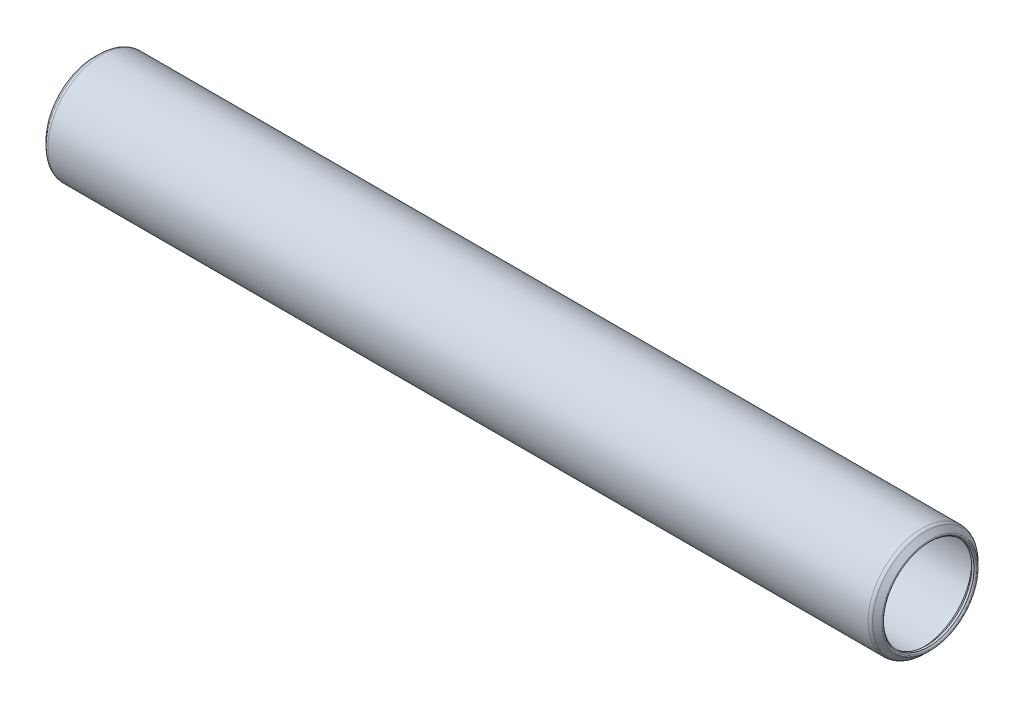
from build123d import *


with BuildPart() as part:
    # Sketch1 → Revolve1 (revolve)
    with BuildSketch(Plane.XY):
        with BuildLine():
            Line((-0.396407684, 5.304957684), (-0.254, 5.16255))
            Line((-0.254, 5.16255), (0, 5.16255))
            Line((0, 5.16255), (0.508, 5.67055))
            Line((0.508, 5.67055), (93.9292, 5.67055))
            Line((93.9292, 5.67055), (94.4372, 5.16255))
            Line((94.4372, 5.16255), (94.6912, 5.16255))
            Line((94.6912, 5.16255), (94.833607684, 5.304957684))
            ThreePointArc((94.833607684, 5.304957684), (94.870805122, 5.394760245), (94.833607684, 5.484562806))
            Line((94.833607684, 5.484562806), (94.301110245, 6.017060245))
            ThreePointArc((94.301110245, 6.017060245), (94.136303184, 6.127180803), (93.9419, 6.16585))
            Line((93.9419, 6.16585), (0.4953, 6.16585))
            ThreePointArc((0.4953, 6.16585), (0.300896816, 6.127180803), (0.136089755, 6.017060245))
            Line((0.136089755, 6.017060245), (-0.396407684, 5.484562806))
            ThreePointArc((-0.396407684, 5.484562806), (-0.433605122, 5.394760245), (-0.396407684, 5.304957684))
        make_face()
    revolve(axis=Axis((94.4372, 0, 0), (-1, 0, 0)))


solid = part.part
